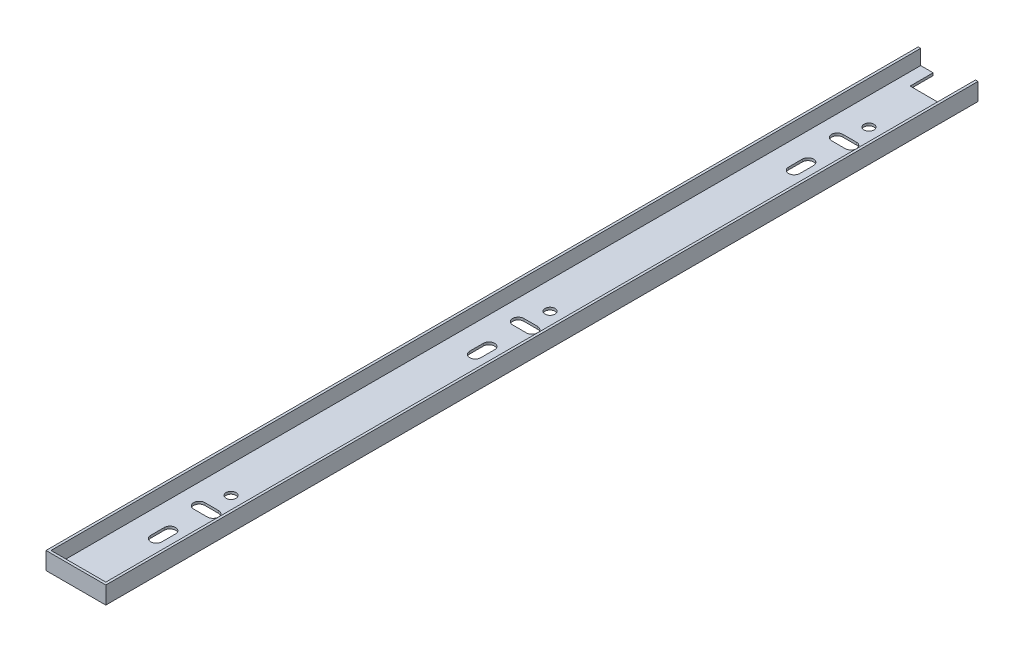
from build123d import *

# Parameters (mm, degrees)
EXTRUDE_1_DEPTH     = 350
SKETCH_2_R          = 2
SKETCH_2_W          = 12
SKETCH_2_H          = 9.239849372
CUT_EXTRUDE_1_DEPTH = 3500
SKETCH_3_W          = 22
SKETCH_3_H          = 1
EXTRUDE_2_DEPTH     = 6


with BuildPart() as part:
    # 草图1 → 凸台-拉伸1 (new body)
    with BuildSketch(Plane.XY):
        Polygon((-12, 3.5), (-11, 3.5), (-11, -2.5), (11, -2.5), (11, 3.5), (12, 3.5), (12, -3.5), (-12, -3.5), align=None)
    extrude(amount=EXTRUDE_1_DEPTH)

    # 草图2 → 切除-拉伸1 (cut)
    with BuildSketch(Plane.XZ.offset(3.5)):
        with Locations((0, 287.75)):
            Circle(SKETCH_2_R)
        with Locations((0, 159.75)):
            Circle(SKETCH_2_R)
        with Locations((0, 31.75)):
            Circle(SKETCH_2_R)
        with BuildLine():
            Line((-2.75, 300), (2.75, 300))
            ThreePointArc((2.75, 300), (5, 297.75), (2.75, 295.5))
            Line((2.75, 295.5), (-2.75, 295.5))
            ThreePointArc((-2.75, 295.5), (-5, 297.75), (-2.75, 300))
        make_face()
        with BuildLine():
            Line((-2.25, 317.75), (-2.25, 312.25))
            ThreePointArc((-2.25, 312.25), (0, 310), (2.25, 312.25))
            Line((2.25, 312.25), (2.25, 317.75))
            ThreePointArc((2.25, 317.75), (0, 320), (-2.25, 317.75))
        make_face()
        with BuildLine():
            Line((-2.25, 189.75), (-2.25, 184.25))
            ThreePointArc((-2.25, 184.25), (0, 182), (2.25, 184.25))
            Line((2.25, 184.25), (2.25, 189.75))
            ThreePointArc((2.25, 189.75), (0, 192), (-2.25, 189.75))
        make_face()
        with BuildLine():
            Line((2.75, 167.5), (-2.75, 167.5))
            ThreePointArc((-2.75, 167.5), (-5, 169.75), (-2.75, 172))
            Line((-2.75, 172), (2.75, 172))
            ThreePointArc((2.75, 172), (5, 169.75), (2.75, 167.5))
        make_face()
        with BuildLine():
            Line((-2.25, 61.75), (-2.25, 56.25))
            ThreePointArc((-2.25, 56.25), (0, 54), (2.25, 56.25))
            Line((2.25, 56.25), (2.25, 61.75))
            ThreePointArc((2.25, 61.75), (0, 64), (-2.25, 61.75))
        make_face()
        with BuildLine():
            Line((2.75, 39.5), (-2.75, 39.5))
            ThreePointArc((-2.75, 39.5), (-5, 41.75), (-2.75, 44))
            Line((-2.75, 44), (2.75, 44))
            ThreePointArc((2.75, 44), (5, 41.75), (2.75, 39.5))
        make_face()
        with Locations((0, 4.619924686)):
            Rectangle(SKETCH_2_W, SKETCH_2_H)
    extrude(amount=-CUT_EXTRUDE_1_DEPTH, mode=Mode.SUBTRACT)

    # 草图3 → 凸台-拉伸2 (add)
    with BuildSketch(Plane(origin=(0, -2.5, 0), x_dir=(1, 0, 0), z_dir=(0, 1, 0))):
        with Locations((0, -349.5)):
            Rectangle(SKETCH_3_W, SKETCH_3_H)
    extrude(amount=EXTRUDE_2_DEPTH)


solid = part.part
